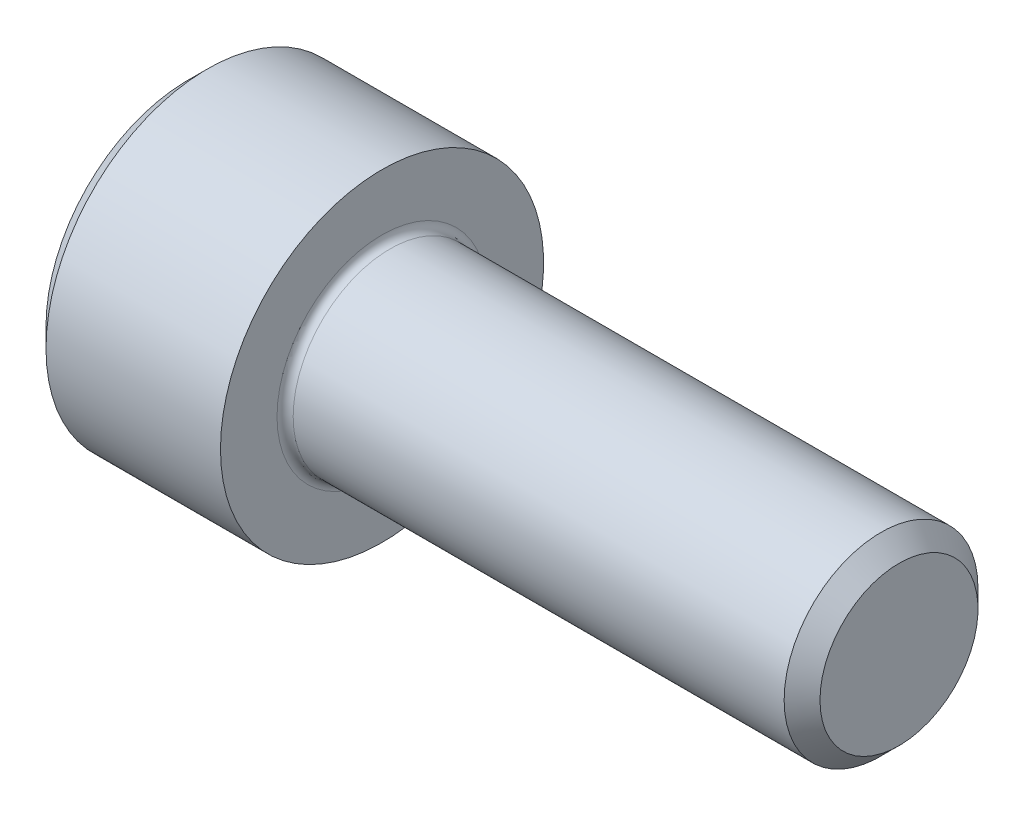
from build123d import *

# Parameters (mm, degrees)
FILLET1_R   = 0.25
HEX_2_DEPTH = 3


with BuildPart() as part:
    # BodySke → Base-Revolve (revolve)
    with BuildSketch(Plane.XY):
        Polygon((0, 0), (0, 4.4), (0.6, 5), (6, 5), (6, 3), (21.4455, 3), (22, 2.4455), (22, 0), align=None)
    revolve(axis=Axis((-31.75, 0, 0), (1, 0, 0)))

    # Fillet1
    fillet1_edges = [part.edges().sort_by_distance(p)[0] for p in [
        (6, -3, 0),
    ]]
    fillet(fillet1_edges, radius=FILLET1_R)

    # Sketch2 → Hex-PreBroach (revolve, cut)
    with BuildSketch(Plane.XY):
        Polygon((0, 2.542), (3, 2.542), (4.467624384, 0), (0, 0), align=None)
    revolve(axis=Axis((0, 0, 0), (1, 0, 0)), mode=Mode.SUBTRACT)

    # Sketch3 → Hex 2 (cut)
    with BuildSketch(Plane(origin=(0, 0, 0), x_dir=(0, 0.5, 0.866025404), z_dir=(-1, 0, 0))):
        Polygon((1.467624384, 2.542), (-1.467624384, 2.542), (-2.935248769, 0), (-1.467624384, -2.542), (1.467624384, -2.542), (2.935248769, 0), align=None)
    extrude(amount=-HEX_2_DEPTH, mode=Mode.SUBTRACT)


solid = part.part
